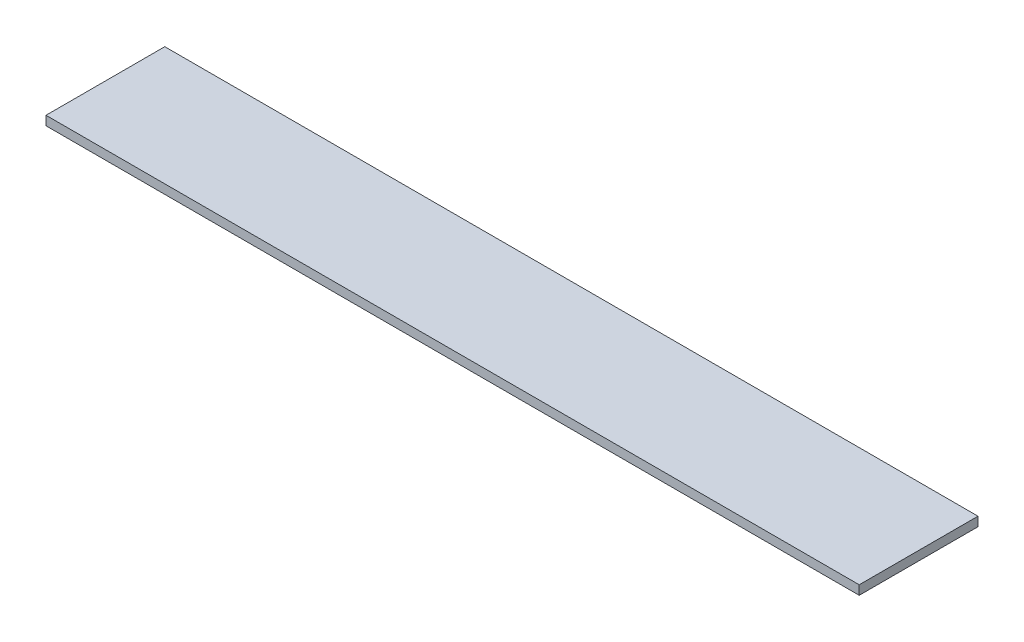
from build123d import *

# Parameters (mm, degrees)
CROQUIS1_W              = 890
CROQUIS1_H              = 130
SALIENTE_EXTRUIR1_DEPTH = 10


with BuildPart() as part:
    # Croquis1 → Saliente-Extruir1 (new body)
    with BuildSketch(Plane(origin=(0, 0, 0), x_dir=(1, 0, 0), z_dir=(0, 1, 0))):
        with Locations((445, 65)):
            Rectangle(CROQUIS1_W, CROQUIS1_H)
    extrude(amount=SALIENTE_EXTRUIR1_DEPTH)


solid = part.part
